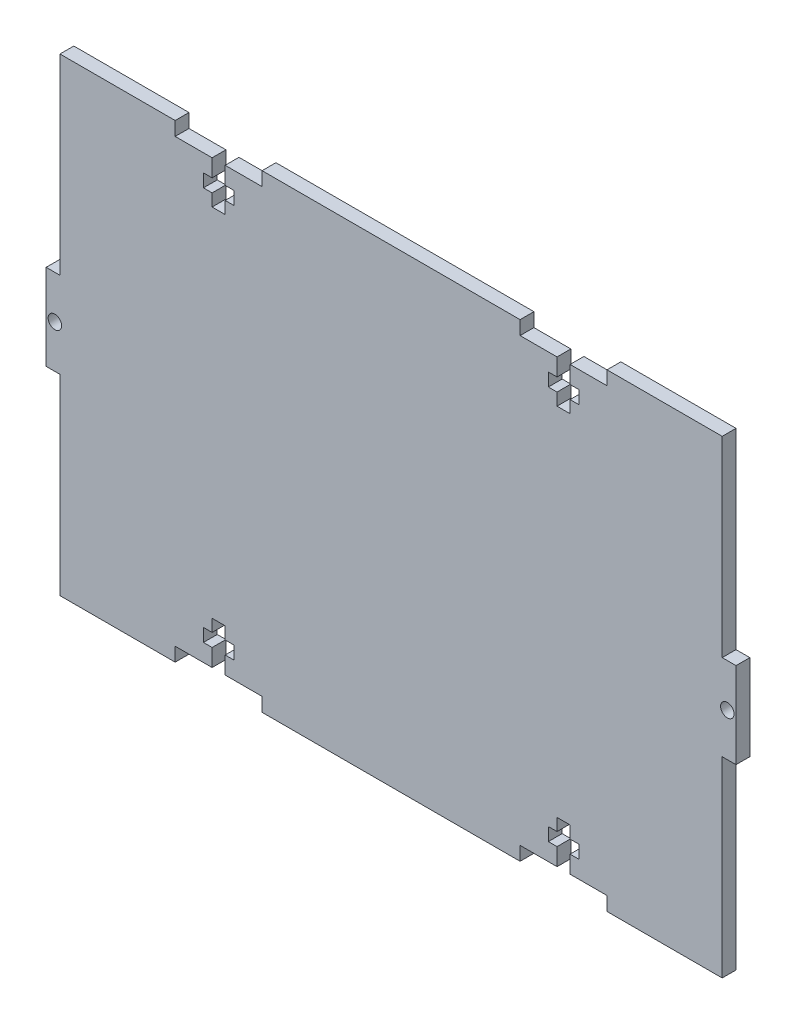
from build123d import *

# Parameters (mm, degrees)
SKETCH2_W               = 158.76
SKETCH2_H               = 107.96
BOSS_EXTRUDE2_DEPTH     = 3.18
CUT_EXTRUDE1_START      = -4.18
CUT_EXTRUDE1_DEPTH      = 5.18
CUT_EXTRUDE2_START      = -4.18
SKETCH4_3_W             = 20
SKETCH4_3_H             = 3.18
CUT_EXTRUDE2_DEPTH      = 5.18
MIRROR2_START           = -4.18
MIRROR2_COPY_1_DEPTH    = 5.18
MIRROR2_COPY_2_SKETCH_W = 20
MIRROR2_COPY_2_SKETCH_H = 3.18
MIRROR2_COPY_2_DEPTH    = 5.18
CUT_EXTRUDE3_START      = -4.18
SKETCH7_W               = 3.18
SKETCH7_H               = 44.105
CUT_EXTRUDE3_DEPTH      = 5.18
MIRROR4_START           = -4.18
MIRROR4_COPY_1_SKETCH_W = 3.18
MIRROR4_COPY_1_SKETCH_H = 44.105
MIRROR4_COPY_1_DEPTH    = 5.18
CUT_EXTRUDE4_START      = -4.18
SKETCH8_R               = 1.55
CUT_EXTRUDE4_DEPTH      = 5.18


with BuildPart() as part:
    # Sketch2 → Boss-Extrude2 (new body)
    with BuildSketch(Plane.XY):
        Rectangle(SKETCH2_W, SKETCH2_H)
    extrude(amount=BOSS_EXTRUDE2_DEPTH)

    # Sketch4 → Cut-Extrude1 (cut)
    with BuildSketch(Plane.XY.offset(3.18).offset(CUT_EXTRUDE1_START)):
        Polygon((41.19, 46.8), (43.19, 46.8), (43.19, 43.8), (41.19, 43.8), (41.19, 40.98), (38.19, 40.98), (38.19, 43.8), (36.19, 43.8), (36.19, 46.8), (38.19, 46.8), (38.19, 50.8), (41.19, 50.8), align=None)
    cut_extrude1 = extrude(amount=CUT_EXTRUDE1_DEPTH, mode=Mode.SUBTRACT)

    # Sketch4_3 → Cut-Extrude2 (cut)
    with BuildSketch(Plane.XY.offset(3.18).offset(CUT_EXTRUDE2_START)):
        Polygon((41.19, 46.8), (43.19, 46.8), (43.19, 43.8), (41.19, 43.8), (41.19, 40.98), (38.19, 40.98), (38.19, 43.8), (36.19, 43.8), (36.19, 46.8), (38.19, 46.8), (38.19, 50.8), (41.19, 50.8), align=None)
        with Locations((39.69, 52.39)):
            Rectangle(SKETCH4_3_W, SKETCH4_3_H)
    cut_extrude2 = extrude(amount=CUT_EXTRUDE2_DEPTH, mode=Mode.SUBTRACT)

    # Mirror1: Cut-Extrude1, Cut-Extrude2 across plane
    add(cut_extrude1.mirror(Plane(origin=(0, 0, 0), x_dir=(0, 0, 1), z_dir=(1, 0, 0))), mode=Mode.SUBTRACT)
    add(cut_extrude2.mirror(Plane(origin=(0, 0, 0), x_dir=(0, 0, 1), z_dir=(1, 0, 0))), mode=Mode.SUBTRACT)

    # Mirror2: Cut-Extrude1, Cut-Extrude2 across plane
    add(cut_extrude1.mirror(Plane.ZX), mode=Mode.SUBTRACT)
    add(cut_extrude2.mirror(Plane.ZX), mode=Mode.SUBTRACT)

    # Mirror2 copy 1 sketch → Mirror2 copy 1 (cut)
    with BuildSketch(Plane(origin=(0, 0, 3.18), x_dir=(-1, 0, 0), z_dir=(0, 0, 1)).offset(MIRROR2_START)):
        Polygon((41.19, 46.8), (43.19, 46.8), (43.19, 43.8), (41.19, 43.8), (41.19, 40.98), (38.19, 40.98), (38.19, 43.8), (36.19, 43.8), (36.19, 46.8), (38.19, 46.8), (38.19, 50.8), (41.19, 50.8), align=None)
    extrude(amount=MIRROR2_COPY_1_DEPTH, mode=Mode.SUBTRACT)

    # Mirror2 copy 2 sketch → Mirror2 copy 2 (cut)
    with BuildSketch(Plane(origin=(0, 0, 3.18), x_dir=(-1, 0, 0), z_dir=(0, 0, 1)).offset(MIRROR2_START)):
        Polygon((41.19, 46.8), (43.19, 46.8), (43.19, 43.8), (41.19, 43.8), (41.19, 40.98), (38.19, 40.98), (38.19, 43.8), (36.19, 43.8), (36.19, 46.8), (38.19, 46.8), (38.19, 50.8), (41.19, 50.8), align=None)
        with Locations((39.69, 52.39)):
            Rectangle(MIRROR2_COPY_2_SKETCH_W, MIRROR2_COPY_2_SKETCH_H)
    extrude(amount=MIRROR2_COPY_2_DEPTH, mode=Mode.SUBTRACT)

    # Sketch7 → Cut-Extrude3 (cut)
    with BuildSketch(Plane.XY.offset(3.18).offset(CUT_EXTRUDE3_START)):
        with Locations((-77.79, 31.9275)):
            Rectangle(SKETCH7_W, SKETCH7_H)
    cut_extrude3 = extrude(amount=CUT_EXTRUDE3_DEPTH, mode=Mode.SUBTRACT)

    # Mirror3: Cut-Extrude3 across plane
    add(cut_extrude3.mirror(Plane.ZX), mode=Mode.SUBTRACT)

    # Mirror4: Cut-Extrude3 across plane
    add(cut_extrude3.mirror(Plane(origin=(0, 0, 0), x_dir=(0, 0, 1), z_dir=(1, 0, 0))), mode=Mode.SUBTRACT)

    # Mirror4 copy 1 sketch → Mirror4 copy 1 (cut)
    with BuildSketch(Plane(origin=(0, 0, 3.18), x_dir=(-1, 0, 0), z_dir=(0, 0, 1)).offset(MIRROR4_START)):
        with Locations((-77.79, 31.9275)):
            Rectangle(MIRROR4_COPY_1_SKETCH_W, MIRROR4_COPY_1_SKETCH_H)
    extrude(amount=MIRROR4_COPY_1_DEPTH, mode=Mode.SUBTRACT)

    # Sketch8 → Cut-Extrude4 (cut)
    with BuildSketch(Plane.XY.offset(3.18).offset(CUT_EXTRUDE4_START)):
        with Locations((-77.38, 0)):
            Circle(SKETCH8_R)
    cut_extrude4 = extrude(amount=CUT_EXTRUDE4_DEPTH, mode=Mode.SUBTRACT)

    # Mirror5: Cut-Extrude4 across plane
    add(cut_extrude4.mirror(Plane(origin=(0, 0, 0), x_dir=(0, 0, 1), z_dir=(1, 0, 0))), mode=Mode.SUBTRACT)


solid = part.part
